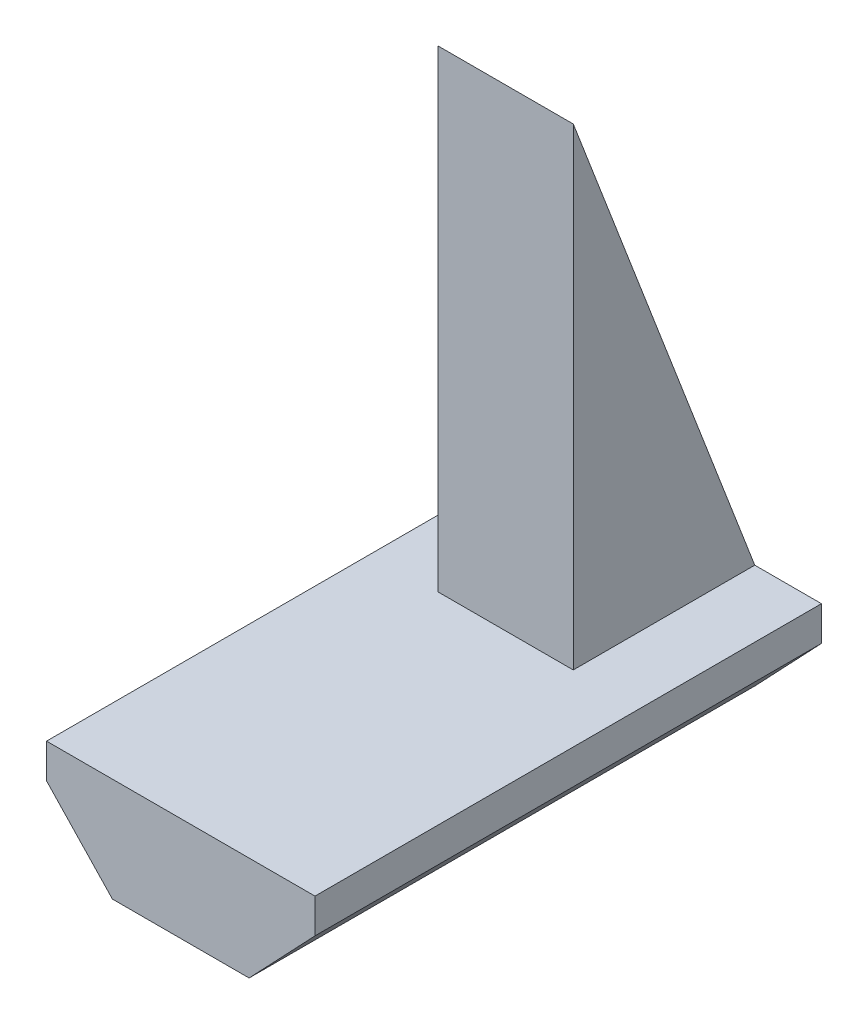
from build123d import *

# Parameters (mm, degrees)
BOSS_EXTRUDE1_DEPTH = 30
BOSS_EXTRUDE3_DEPTH = 4


with BuildPart() as part:
    # Sketch1 → Boss-Extrude1 (new body)
    with BuildSketch(Plane.XY):
        Polygon((7.95, 0), (7.95, -2.04), (4.048, -6.152414984), (-4.048, -6.152414984), (-7.95, -2.04), (-7.95, 0), align=None)
    extrude(amount=BOSS_EXTRUDE1_DEPTH)

    # Sketch2 → Boss-Extrude3 (add, symmetric)
    with BuildSketch(Plane.ZY):
        Polygon((0, 0), (10.751038486, 28.007412795), (10.751038486, 0), align=None)
    extrude(amount=BOSS_EXTRUDE3_DEPTH, both=True)


solid = part.part
